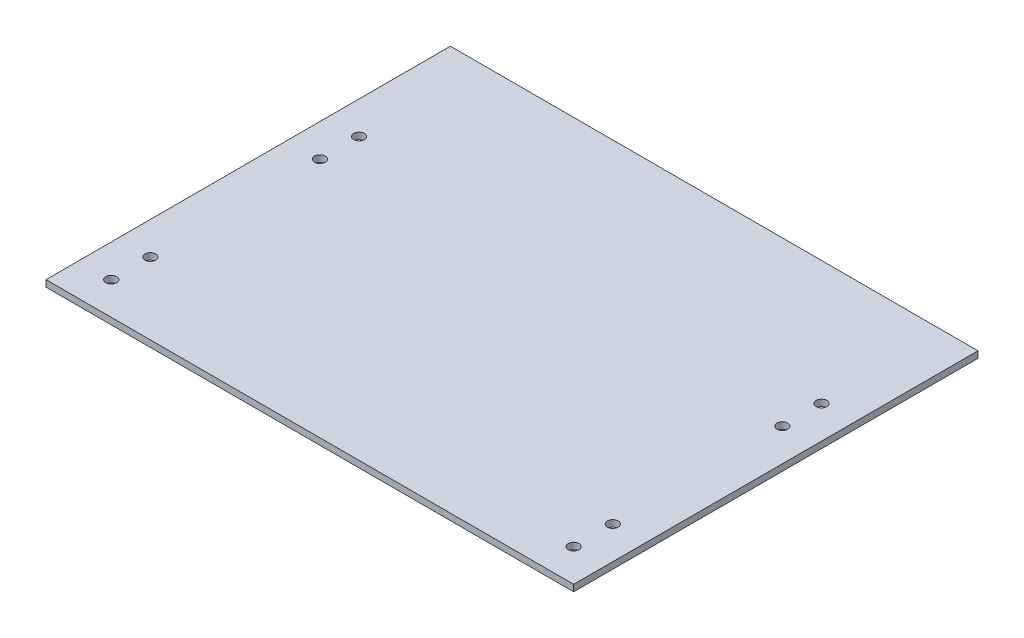
from build123d import *

# Parameters (mm, degrees)
SKETCH1_W           = 161.8
SKETCH1_H           = 124
SKETCH1_R           = 1.65
BOSS_EXTRUDE1_DEPTH = 2


with BuildPart() as part:
    # Sketch1 → Boss-Extrude1 (new body)
    with BuildSketch(Plane(origin=(0, 0, 0), x_dir=(1, 0, 0), z_dir=(0, 1, 0))):
        with Locations((0, 14)):
            Rectangle(SKETCH1_W, SKETCH1_H)
        with Locations((-70.9, 38)):
            Circle(SKETCH1_R, mode=Mode.SUBTRACT)
        with Locations((-70.9, 26)):
            Circle(SKETCH1_R, mode=Mode.SUBTRACT)
        with Locations((-70.9, -26)):
            Circle(SKETCH1_R, mode=Mode.SUBTRACT)
        with Locations((-70.9, -38)):
            Circle(SKETCH1_R, mode=Mode.SUBTRACT)
        with Locations((70.9, 38)):
            Circle(SKETCH1_R, mode=Mode.SUBTRACT)
        with Locations((70.9, 26)):
            Circle(SKETCH1_R, mode=Mode.SUBTRACT)
        with Locations((70.9, -26)):
            Circle(SKETCH1_R, mode=Mode.SUBTRACT)
        with Locations((70.9, -38)):
            Circle(SKETCH1_R, mode=Mode.SUBTRACT)
    extrude(amount=BOSS_EXTRUDE1_DEPTH)


solid = part.part
